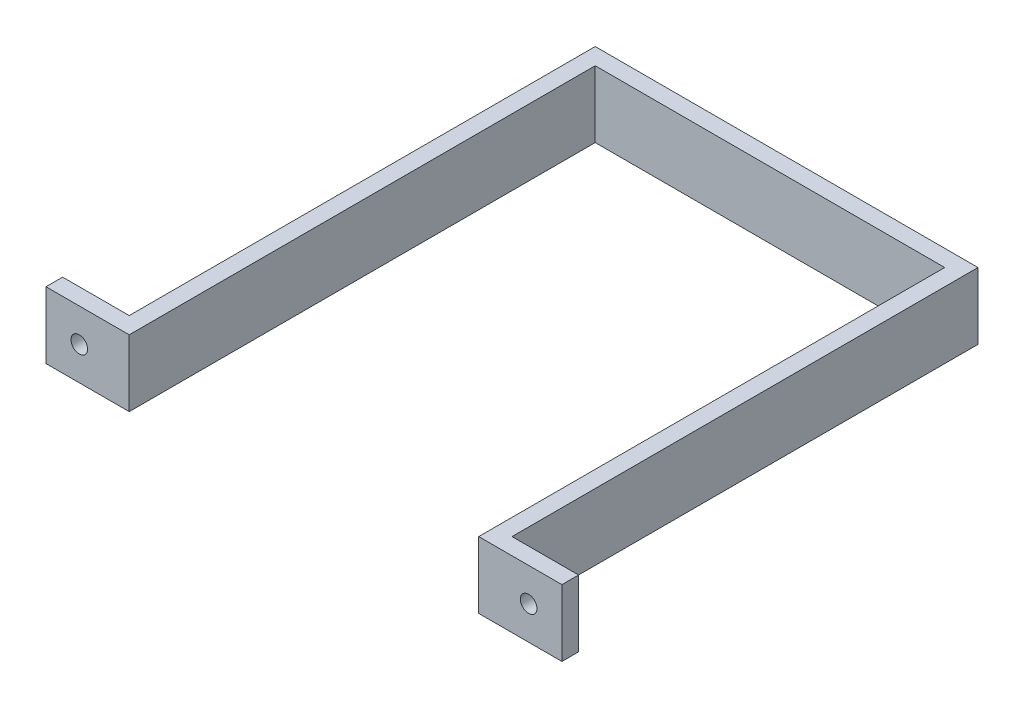
from build123d import *

# Parameters (mm, degrees)
BOSS_EXTRUDE1_DEPTH = 20
SKETCH2_R           = 2.5
CUT_EXTRUDE1_DEPTH  = 20


with BuildPart() as part:
    # Sketch1 → Boss-Extrude1 (new body)
    with BuildSketch(Plane(origin=(0, 0, 0), x_dir=(1, 0, 0), z_dir=(0, 1, 0))):
        Polygon((52.5, -70), (77.5, -70), (77.5, -65), (57.5, -65), (57.5, 75), (-57.5, 75), (-57.5, -65), (-77.5, -65), (-77.5, -70), (-52.5, -70), (-52.5, 70), (52.5, 70), align=None)
    extrude(amount=BOSS_EXTRUDE1_DEPTH)

    # Sketch2 → Cut-Extrude1 (cut)
    with BuildSketch(Plane(origin=(0, 0, 65), x_dir=(-1, 0, 0), z_dir=(0, 0, -1))):
        with Locations((-67.5, 10)):
            Circle(SKETCH2_R)
        with Locations((67.5, 10)):
            Circle(SKETCH2_R)
    extrude(amount=-CUT_EXTRUDE1_DEPTH, mode=Mode.SUBTRACT)


solid = part.part
